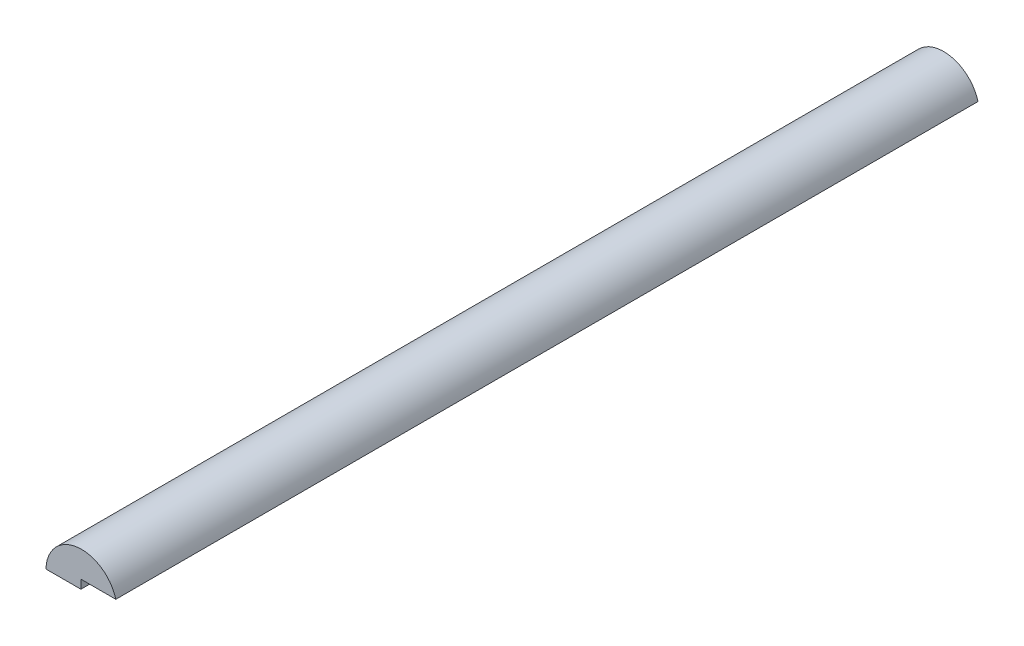
from build123d import *

# Parameters (mm, degrees)
BOSS_EXTRUDE1_DEPTH = 12.35


with BuildPart() as part:
    # Sketch1 → Boss-Extrude1 (new body, symmetric)
    with BuildSketch(Plane.XY):
        with BuildLine():
            Line((0, 0), (0, -0.25))
            Line((0, -0.25), (-1, -0.25))
            ThreePointArc((-1, -0.25), (-0.108392321, 0.742138571), (1, 0))
            Line((1, 0), (0, 0))
        make_face()
    extrude(amount=BOSS_EXTRUDE1_DEPTH, both=True)


solid = part.part
